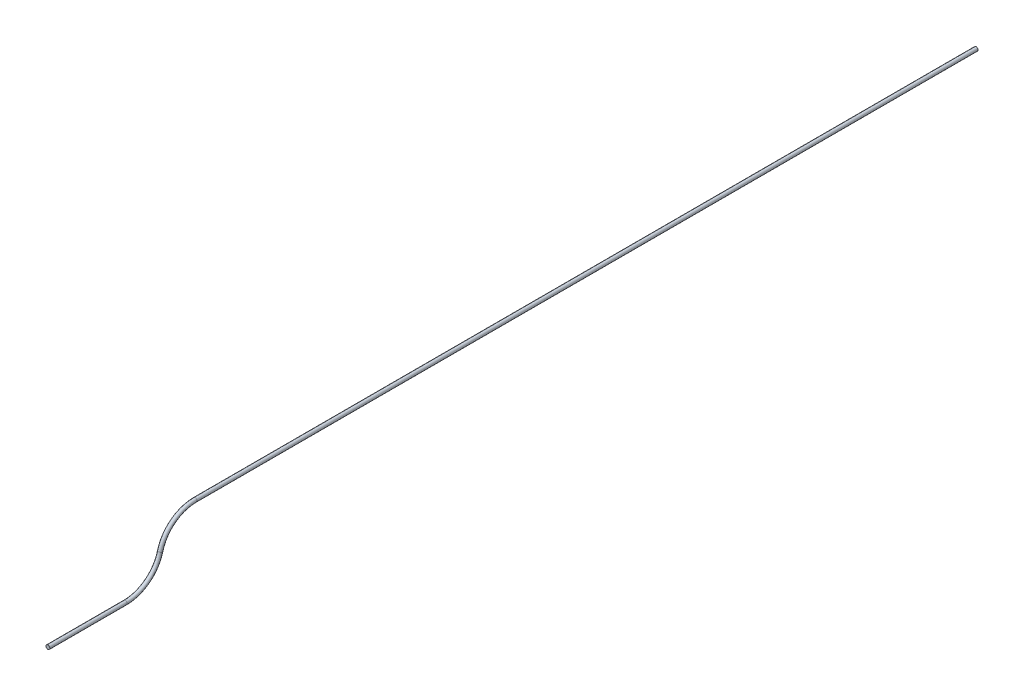
from build123d import *

# Parameters (mm, degrees)
SKETCH1_R = 4.03225


with BuildPart() as part:
    # Sweep1: sweep along a path in Sketch2
    with BuildLine(Plane(origin=(0, 0, 0), x_dir=(0, 0, -1), z_dir=(1, 0, 0))) as sweep1_path:
        Line((0, 0), (163.5, 0))
        ThreePointArc((163.5, 0), (210.1627796, 15.958610574), (237.280332745, 57.15))
        ThreePointArc((237.280332745, 57.15), (264.39788589, 98.341389426), (311.060665491, 114.3))
        Line((311.060665491, 114.3), (1962.060665491, 114.3))
    # Sketch1 → Sweep1 (sweep)
    with BuildSketch(Plane.XY):
        Circle(SKETCH1_R)
    sweep(path=sweep1_path.line)


solid = part.part
